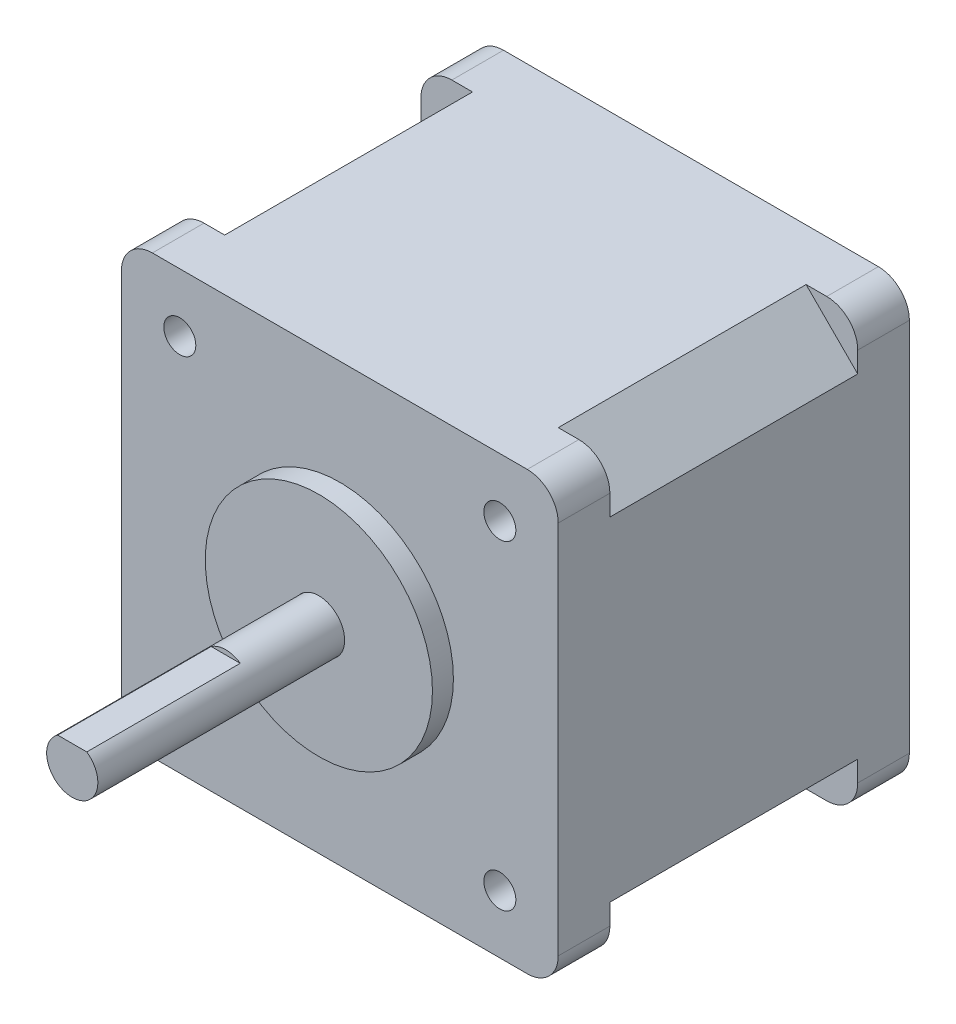
from build123d import *

# Parameters (mm, degrees)
BOSS_EXTRUDE1_DEPTH     = 34
SKETCH1_3_R             = 1.55
CUT_EXTRUDE1_DEPTH      = 4
SKETCH2_R               = 1.55
CUT_EXTRUDE2_DEPTH      = 4
SKETCH3_R               = 11
BOSS_EXTRUDE2_DEPTH     = 2.03
SKETCH4_R               = 2.495
CUT_EXTRUDE3_DEPTH      = 12.03
SKETCH5_R               = 2.48
BOSS_EXTRUDE5_DEPTH     = 35.91
CUT_EXTRUDE4_DEPTH      = 1
CUT_EXTRUDE4_DEPTH_BACK = 14.86
CUT_EXTRUDE5_DEPTH      = 12
CUT_EXTRUDE5_DEPTH_BACK = 12


with BuildPart() as part:
    # Sketch1 → Boss-Extrude1 (new body)
    with BuildSketch(Plane.XY):
        with BuildLine():
            Line((-18.15, 21.15), (18.15, 21.15))
            ThreePointArc((18.15, 21.15), (20.271320344, 20.271320344), (21.15, 18.15))
            Line((21.15, 18.15), (21.15, -18.15))
            ThreePointArc((21.15, -18.15), (20.271320344, -20.271320344), (18.15, -21.15))
            Line((18.15, -21.15), (-18.15, -21.15))
            ThreePointArc((-18.15, -21.15), (-20.271320344, -20.271320344), (-21.15, -18.15))
            Line((-21.15, -18.15), (-21.15, 18.15))
            ThreePointArc((-21.15, 18.15), (-20.271320344, 20.271320344), (-18.15, 21.15))
        make_face()
    extrude(amount=BOSS_EXTRUDE1_DEPTH)

    # Sketch1_3 → Cut-Extrude1 (cut)
    with BuildSketch(Plane.XY):
        with Locations((-15.495, 15.494592339)):
            Circle(SKETCH1_3_R)
        with Locations((15.495, 15.494592339)):
            Circle(SKETCH1_3_R)
        with Locations((15.495, -15.494592339)):
            Circle(SKETCH1_3_R)
        with Locations((-15.495, -15.494592339)):
            Circle(SKETCH1_3_R)
    extrude(amount=CUT_EXTRUDE1_DEPTH, mode=Mode.SUBTRACT)

    # Sketch2 → Cut-Extrude2 (cut)
    with BuildSketch(Plane.XY.offset(34)):
        with Locations((-15.495, 15.494592339)):
            Circle(SKETCH2_R)
        with Locations((15.495, 15.494592339)):
            Circle(SKETCH2_R)
        with Locations((15.495, -15.494592339)):
            Circle(SKETCH2_R)
        with Locations((-15.495, -15.494592339)):
            Circle(SKETCH2_R)
    extrude(amount=-CUT_EXTRUDE2_DEPTH, mode=Mode.SUBTRACT)

    # Sketch3 → Boss-Extrude2 (add)
    with BuildSketch(Plane.XY.offset(34)):
        Circle(SKETCH3_R)
    extrude(amount=BOSS_EXTRUDE2_DEPTH)

    # Sketch4 → Cut-Extrude3 (cut)
    with BuildSketch(Plane.XY.offset(36.03)):
        Circle(SKETCH4_R)
    extrude(amount=-CUT_EXTRUDE3_DEPTH, mode=Mode.SUBTRACT)

    # Sketch5 → Boss-Extrude5 (add)
    with BuildSketch(Plane.XY.offset(24)):
        Circle(SKETCH5_R)
    extrude(amount=BOSS_EXTRUDE5_DEPTH)

    # Sketch6 → Cut-Extrude4 (cut, two sides)
    with BuildSketch(Plane.XY.offset(59.91)) as cut_extrude4_sk:
        Polygon((-76.179783434, 2.04), (-1.436462669, 2.04), (1.410248205, 2.04), (76.15356897, 2.04), (76.15356897, 151.526641529), (-76.179783434, 151.526641529), align=None)
    extrude(amount=CUT_EXTRUDE4_DEPTH, mode=Mode.SUBTRACT)
    extrude(cut_extrude4_sk.sketch, amount=-CUT_EXTRUDE4_DEPTH_BACK, mode=Mode.SUBTRACT)

    # Sketch7 → Cut-Extrude5 (cut, two sides)
    with BuildSketch(Plane.XY.offset(17)) as cut_extrude5_sk:
        Polygon((16.15, 21.15), (21.15, 16.15), (21.15, 21.15), align=None)
        Polygon((-16.15, 21.15), (-21.15, 16.15), (-21.15, 21.15), align=None)
        Polygon((16.15, -21.15), (21.15, -16.15), (21.15, -21.15), align=None)
        Polygon((-16.15, -21.15), (-21.15, -16.15), (-21.15, -21.15), align=None)
    extrude(amount=CUT_EXTRUDE5_DEPTH, mode=Mode.SUBTRACT)
    extrude(cut_extrude5_sk.sketch, amount=-CUT_EXTRUDE5_DEPTH_BACK, mode=Mode.SUBTRACT)


solid = part.part
